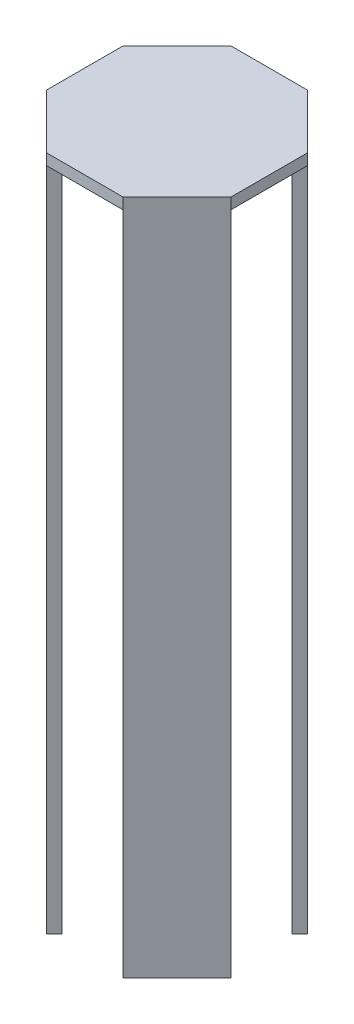
from build123d import *

# Parameters (mm, degrees)
RESSALTO_EXTRUS_O1_DEPTH   = 180
RESSALTO_EXTRUS_O1_2_DEPTH = 180
RESSALTO_EXTRUS_O1_3_DEPTH = 180
RESSALTO_EXTRUS_O1_4_DEPTH = 180
RESSALTO_EXTRUS_O2_DEPTH   = 3


with BuildPart() as part:
    # Esboço1 → Ressalto-extrusão1 (new body)
    with BuildSketch(Plane(origin=(0, 0, 0), x_dir=(1, 0, 0), z_dir=(0, 1, 0))):
        Polygon((-25, 10.355339059), (-10.355339059, 25), (-8.234018716, 22.878679656), (-22.878679656, 8.234018716), align=None)
    extrude(amount=RESSALTO_EXTRUS_O1_DEPTH)



with BuildPart() as body_2:
    # Esboço1 → Ressalto-extrus_o1 2 (new body)
    with BuildSketch(Plane(origin=(0, 0, 0), x_dir=(1, 0, 0), z_dir=(0, 1, 0))):
        Polygon((10.355339059, 25), (25, 10.355339059), (22.878679656, 8.234018716), (8.234018716, 22.878679656), align=None)
    extrude(amount=RESSALTO_EXTRUS_O1_2_DEPTH)


with BuildPart() as body_3:
    # Esboço1 → Ressalto-extrus_o1 3 (new body)
    with BuildSketch(Plane(origin=(0, 0, 0), x_dir=(1, 0, 0), z_dir=(0, 1, 0))):
        Polygon((25, -10.355339059), (10.355339059, -25), (8.234018716, -22.878679656), (22.878679656, -8.234018716), align=None)
    extrude(amount=RESSALTO_EXTRUS_O1_3_DEPTH)


with BuildPart() as body_4:
    # Esboço1 → Ressalto-extrus_o1 4 (new body)
    with BuildSketch(Plane(origin=(0, 0, 0), x_dir=(1, 0, 0), z_dir=(0, 1, 0))):
        Polygon((-10.355339059, -25), (-25, -10.355339059), (-22.878679656, -8.234018716), (-8.234018716, -22.878679656), align=None)
    extrude(amount=RESSALTO_EXTRUS_O1_4_DEPTH)


with BuildPart() as part_1:
    add(part.part)

    add(body_2.part)  # Ressalto-extrusão2 merges body 2

    add(body_3.part)  # Ressalto-extrusão2 merges body 3

    add(body_4.part)  # Ressalto-extrusão2 merges body 4
    # Esboço2 → Ressalto-extrusão2 (add)
    with BuildSketch(Plane(origin=(0, 180, 0), x_dir=(1, 0, 0), z_dir=(0, 1, 0))):
        Polygon((-10.355339059, 25), (10.355339059, 25), (25, 10.355339059), (25, -10.355339059), (10.355339059, -25), (-10.355339059, -25), (-25, -10.355339059), (-25, 10.355339059), align=None)
    extrude(amount=RESSALTO_EXTRUS_O2_DEPTH)


solid = part_1.part
